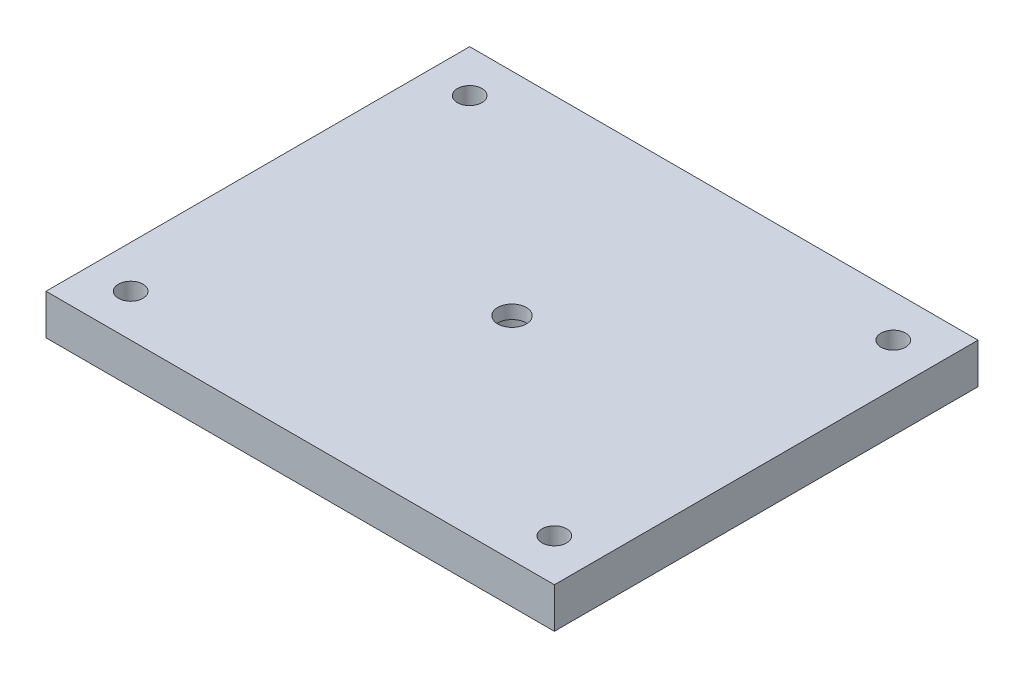
from build123d import *

# Parameters (mm, degrees)
SKETCH1_W                                        = 120
SKETCH1_H                                        = 100
BOSS_EXTRUDE1_DEPTH                              = 9.525
M5_CLEARANCE_HOLE1_D                             = 5.8
CBORE_FOR_1_4_SOCKET_HEAD_CAP_SCREW1_D           = 6.7564
CBORE_FOR_1_4_SOCKET_HEAD_CAP_SCREW1_CBORE_D     = 11.1125
CBORE_FOR_1_4_SOCKET_HEAD_CAP_SCREW1_CBORE_DEPTH = 6.35


with BuildPart() as part:
    # Sketch1 → Boss-Extrude1 (new body)
    with BuildSketch(Plane(origin=(0, 0, 0), x_dir=(1, 0, 0), z_dir=(0, 1, 0))):
        Rectangle(SKETCH1_W, SKETCH1_H)
    extrude(amount=BOSS_EXTRUDE1_DEPTH)

    # M5 Clearance Hole1 (through all)
    with Locations(Plane(origin=(0, 9.525, 0), x_dir=(1, 0, 0), z_dir=(0, 1, 0))):
        with Locations((-50, -40), (-50, 40), (50, 40), (50, -40)):
            Hole(M5_CLEARANCE_HOLE1_D / 2)

    # CBORE for 1_4 Socket Head Cap Screw1 (through all)
    with Locations(Plane(origin=(0, 0, 0), x_dir=(-1, 0, 0), z_dir=(0, -1, 0))):
        with Locations((0, 0)):
            CounterBoreHole(CBORE_FOR_1_4_SOCKET_HEAD_CAP_SCREW1_D / 2, CBORE_FOR_1_4_SOCKET_HEAD_CAP_SCREW1_CBORE_D / 2, CBORE_FOR_1_4_SOCKET_HEAD_CAP_SCREW1_CBORE_DEPTH)


solid = part.part
